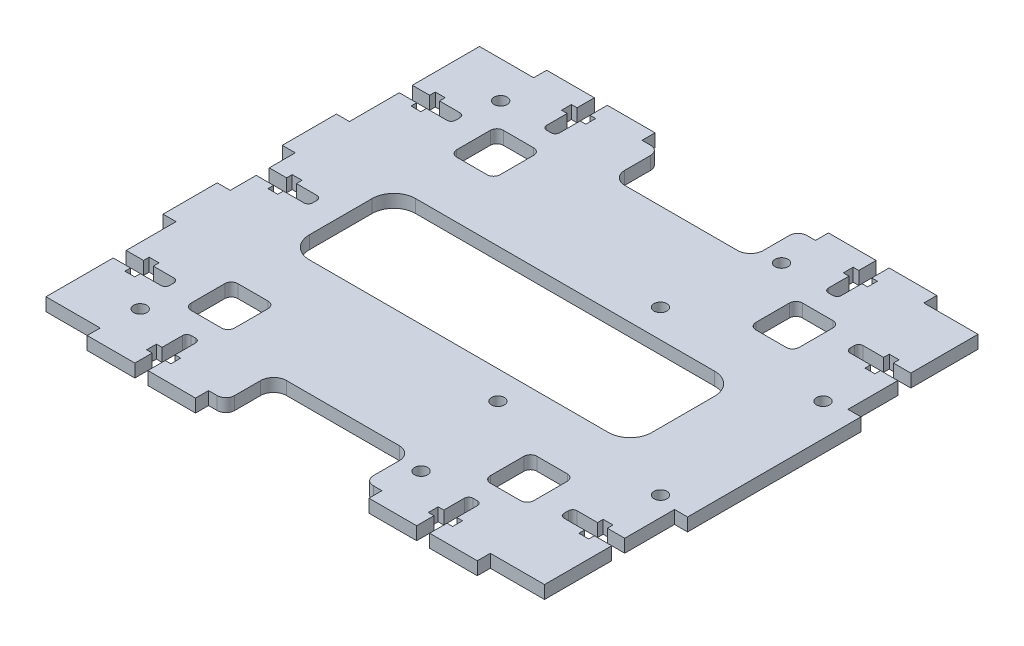
from build123d import *

# Parameters (mm, degrees)
ESBO_O1_W                  = 115
ESBO_O1_H                  = 100
RESSALTO_EXTRUS_O1_DEPTH   = 1.5
ESBO_O4_W                  = 3
ESBO_O4_H                  = 40
ESBO_O4_W_2                = 25
ESBO_O4_H_2                = 3
RESSALTO_EXTRUS_O2_DEPTH   = 3
CORTE_EXTRUS_O1_DEPTH      = 4
CORTE_EXTRUS_O4_DEPTH      = 4
ESBO_O13_R                 = 1.5
CORTE_EXTRUS_O8_DEPTH      = 1
CORTE_EXTRUS_O8_DEPTH_BACK = 4
CUT_EXTRUDE3_DEPTH         = 2.5
CUT_EXTRUDE3_DEPTH_BACK    = 2.5
CUT_EXTRUDE4_DEPTH         = 2.5
CUT_EXTRUDE4_DEPTH_BACK    = 2.5
CUT_EXTRUDE5_DEPTH         = 2.5
CUT_EXTRUDE5_DEPTH_BACK    = 2.5
FILLET1_R                  = 2
CUT_EXTRUDE6_DEPTH         = 2.5
CUT_EXTRUDE6_DEPTH_BACK    = 2.5
SKETCH8_R                  = 1.5
CUT_EXTRUDE7_DEPTH         = 1
CUT_EXTRUDE7_DEPTH_BACK    = 4


with BuildPart() as part:
    # Esboço1 → Ressalto-extrusão1 (new body, symmetric)
    with BuildSketch(Plane(origin=(0, 0, 0), x_dir=(1, 0, 0), z_dir=(0, 1, 0))):
        Rectangle(ESBO_O1_W, ESBO_O1_H)
    extrude(amount=RESSALTO_EXTRUS_O1_DEPTH, both=True)

    # Esboço4 → Ressalto-extrusão2 (add, through all)
    with BuildSketch(Plane(origin=(0, 1.5, 0), x_dir=(1, 0, 0), z_dir=(0, 1, 0))):
        with Locations((-59, 0)):
            Rectangle(ESBO_O4_W, ESBO_O4_H)
        with Locations((-32.5, -51.5)):
            Rectangle(ESBO_O4_W_2, ESBO_O4_H_2)
        with Locations((59, 0)):
            Rectangle(ESBO_O4_W, ESBO_O4_H)
        with Locations((32.5, -51.5)):
            Rectangle(ESBO_O4_W_2, ESBO_O4_H_2)
        with Locations((32.5, 51.5)):
            Rectangle(ESBO_O4_W_2, ESBO_O4_H_2)
        with Locations((-32.5, 51.5)):
            Rectangle(ESBO_O4_W_2, ESBO_O4_H_2)
    extrude(amount=-RESSALTO_EXTRUS_O2_DEPTH)

    # Esboço2 → Corte-extrusão1 (cut, through all)
    with BuildSketch(Plane(origin=(0, 1.5, 0), x_dir=(1, 0, 0), z_dir=(0, 1, 0))):
        with BuildLine():
            Line((-34, -53), (-31, -53))
            Line((-31, -53), (-31, -49))
            Line((-31, -49), (-29.7, -49))
            Line((-29.7, -49), (-29.7, -46.73))
            Line((-29.7, -46.73), (-31, -46.73))
            Line((-31, -46.73), (-31, -42))
            ThreePointArc((-31, -42), (-31.292893219, -41.292893219), (-32, -41))
            Line((-32, -41), (-33, -41))
            ThreePointArc((-33, -41), (-33.707106781, -41.292893219), (-34, -42))
            Line((-34, -42), (-34, -46.73))
            Line((-34, -46.73), (-35.3, -46.73))
            Line((-35.3, -46.73), (-35.3, -49))
            Line((-35.3, -49), (-34, -49))
            Line((-34, -49), (-34, -53))
        make_face()
        with BuildLine():
            Line((31, -46.73), (31, -42))
            ThreePointArc((31, -42), (31.292893219, -41.292893219), (32, -41))
            Line((32, -41), (33, -41))
            ThreePointArc((33, -41), (33.707106781, -41.292893219), (34, -42))
            Line((34, -42), (34, -46.73))
            Line((34, -46.73), (35.3, -46.73))
            Line((35.3, -46.73), (35.3, -49))
            Line((35.3, -49), (34, -49))
            Line((34, -49), (34, -53))
            Line((34, -53), (31, -53))
            Line((31, -53), (31, -49))
            Line((31, -49), (29.7, -49))
            Line((29.7, -49), (29.7, -46.73))
            Line((29.7, -46.73), (31, -46.73))
        make_face()
        with BuildLine():
            Line((34, 53), (31, 53))
            Line((31, 53), (31, 49))
            Line((31, 49), (29.7, 49))
            Line((29.7, 49), (29.7, 46.73))
            Line((29.7, 46.73), (31, 46.73))
            Line((31, 46.73), (31, 42))
            ThreePointArc((31, 42), (31.292893219, 41.292893219), (32, 41))
            Line((32, 41), (33, 41))
            ThreePointArc((33, 41), (33.707106781, 41.292893219), (34, 42))
            Line((34, 42), (34, 46.73))
            Line((34, 46.73), (35.3, 46.73))
            Line((35.3, 46.73), (35.3, 49))
            Line((35.3, 49), (34, 49))
            Line((34, 49), (34, 53))
        make_face()
        with BuildLine():
            Line((-31, 46.73), (-31, 42))
            ThreePointArc((-31, 42), (-31.292893219, 41.292893219), (-32, 41))
            Line((-32, 41), (-33, 41))
            ThreePointArc((-33, 41), (-33.707106781, 41.292893219), (-34, 42))
            Line((-34, 42), (-34, 46.73))
            Line((-34, 46.73), (-35.3, 46.73))
            Line((-35.3, 46.73), (-35.3, 49))
            Line((-35.3, 49), (-34, 49))
            Line((-34, 49), (-34, 53))
            Line((-34, 53), (-31, 53))
            Line((-31, 53), (-31, 49))
            Line((-31, 49), (-29.7, 49))
            Line((-29.7, 49), (-29.7, 46.73))
            Line((-29.7, 46.73), (-31, 46.73))
        make_face()
    extrude(amount=-CORTE_EXTRUS_O1_DEPTH, mode=Mode.SUBTRACT)

    # Esboço7 → Corte-extrusão4 (cut, through all)
    with BuildSketch(Plane(origin=(0, 1.5, 0), x_dir=(1, 0, 0), z_dir=(0, 1, 0))):
        with BuildLine():
            Line((-57.5, -31.5), (-53.5, -31.5))
            Line((-53.5, -31.5), (-53.5, -30.2))
            Line((-53.5, -30.2), (-51.23, -30.2))
            Line((-51.23, -30.2), (-51.23, -31.5))
            Line((-51.23, -31.5), (-46.5, -31.5))
            ThreePointArc((-46.5, -31.5), (-45.792893219, -31.792893219), (-45.5, -32.5))
            Line((-45.5, -32.5), (-45.5, -33.5))
            ThreePointArc((-45.5, -33.5), (-45.792893219, -34.207106781), (-46.5, -34.5))
            Line((-46.5, -34.5), (-51.23, -34.5))
            Line((-51.23, -34.5), (-51.23, -35.8))
            Line((-51.23, -35.8), (-53.5, -35.8))
            Line((-53.5, -35.8), (-53.5, -34.5))
            Line((-53.5, -34.5), (-57.5, -34.5))
            Line((-57.5, -34.5), (-57.5, -31.5))
        make_face()
        with BuildLine():
            Line((53.5, -34.5), (53.5, -35.8))
            Line((53.5, -35.8), (51.23, -35.8))
            Line((51.23, -35.8), (51.23, -34.5))
            Line((51.23, -34.5), (46.5, -34.5))
            ThreePointArc((46.5, -34.5), (45.792893219, -34.207106781), (45.5, -33.5))
            Line((45.5, -33.5), (45.5, -32.5))
            ThreePointArc((45.5, -32.5), (45.792893219, -31.792893219), (46.5, -31.5))
            Line((46.5, -31.5), (51.23, -31.5))
            Line((51.23, -31.5), (51.23, -30.2))
            Line((51.23, -30.2), (53.5, -30.2))
            Line((53.5, -30.2), (53.5, -31.5))
            Line((53.5, -31.5), (57.5, -31.5))
            Line((57.5, -31.5), (57.5, -34.5))
            Line((57.5, -34.5), (53.5, -34.5))
        make_face()
        with BuildLine():
            Line((57.5, 31.5), (53.5, 31.5))
            Line((53.5, 31.5), (53.5, 30.2))
            Line((53.5, 30.2), (51.23, 30.2))
            Line((51.23, 30.2), (51.23, 31.5))
            Line((51.23, 31.5), (46.5, 31.5))
            ThreePointArc((46.5, 31.5), (45.792893219, 31.792893219), (45.5, 32.5))
            Line((45.5, 32.5), (45.5, 33.5))
            ThreePointArc((45.5, 33.5), (45.792893219, 34.207106781), (46.5, 34.5))
            Line((46.5, 34.5), (51.23, 34.5))
            Line((51.23, 34.5), (51.23, 35.8))
            Line((51.23, 35.8), (53.5, 35.8))
            Line((53.5, 35.8), (53.5, 34.5))
            Line((53.5, 34.5), (57.5, 34.5))
            Line((57.5, 34.5), (57.5, 31.5))
        make_face()
        with BuildLine():
            Line((-53.5, 34.5), (-53.5, 35.8))
            Line((-53.5, 35.8), (-51.23, 35.8))
            Line((-51.23, 35.8), (-51.23, 34.5))
            Line((-51.23, 34.5), (-46.5, 34.5))
            ThreePointArc((-46.5, 34.5), (-45.792893219, 34.207106781), (-45.5, 33.5))
            Line((-45.5, 33.5), (-45.5, 32.5))
            ThreePointArc((-45.5, 32.5), (-45.792893219, 31.792893219), (-46.5, 31.5))
            Line((-46.5, 31.5), (-51.23, 31.5))
            Line((-51.23, 31.5), (-51.23, 30.2))
            Line((-51.23, 30.2), (-53.5, 30.2))
            Line((-53.5, 30.2), (-53.5, 31.5))
            Line((-53.5, 31.5), (-57.5, 31.5))
            Line((-57.5, 31.5), (-57.5, 34.5))
            Line((-57.5, 34.5), (-53.5, 34.5))
        make_face()
    extrude(amount=-CORTE_EXTRUS_O4_DEPTH, mode=Mode.SUBTRACT)

    # Esboço13 → Corte-extrusão8 (cut, two sides)
    with BuildSketch(Plane(origin=(0, -1.5, 0), x_dir=(-1, 0, 0), z_dir=(0, -1, 0))) as corte_extrus_o8_sk:
        with Locations((-15.5, -18.75)):
            Circle(ESBO_O13_R)
        with Locations((-53, -18.75)):
            Circle(ESBO_O13_R)
        with Locations((-15.5, 18.75)):
            Circle(ESBO_O13_R)
        with Locations((-53, 18.75)):
            Circle(ESBO_O13_R)
    extrude(amount=CORTE_EXTRUS_O8_DEPTH, mode=Mode.SUBTRACT)
    extrude(corte_extrus_o8_sk.sketch, amount=-CORTE_EXTRUS_O8_DEPTH_BACK, mode=Mode.SUBTRACT)

    # Sketch4 → Cut-Extrude3 (cut, two sides)
    with BuildSketch(Plane(origin=(0, 0, 0), x_dir=(1, 0, 0), z_dir=(0, 1, 0))) as cut_extrude3_sk:
        with BuildLine():
            Line((-38, 36), (-31, 36))
            ThreePointArc((-31, 36), (-29.939339828, 35.560660172), (-29.5, 34.5))
            Line((-29.5, 34.5), (-29.5, 26.75))
            ThreePointArc((-29.5, 26.75), (-29.939339828, 25.689339828), (-31, 25.25))
            Line((-31, 25.25), (-38, 25.25))
            ThreePointArc((-38, 25.25), (-39.060660172, 25.689339828), (-39.5, 26.75))
            Line((-39.5, 26.75), (-39.5, 34.5))
            ThreePointArc((-39.5, 34.5), (-39.060660172, 35.560660172), (-38, 36))
        make_face()
        with BuildLine():
            Line((29.5, 34.5), (29.5, 26.75))
            ThreePointArc((29.5, 26.75), (29.939339828, 25.689339828), (31, 25.25))
            Line((31, 25.25), (38, 25.25))
            ThreePointArc((38, 25.25), (39.060660172, 25.689339828), (39.5, 26.75))
            Line((39.5, 26.75), (39.5, 34.5))
            ThreePointArc((39.5, 34.5), (39.060660172, 35.560660172), (38, 36))
            Line((38, 36), (31, 36))
            ThreePointArc((31, 36), (29.939339828, 35.560660172), (29.5, 34.5))
        make_face()
        with BuildLine():
            Line((38, -36), (31, -36))
            ThreePointArc((31, -36), (29.939339828, -35.560660172), (29.5, -34.5))
            Line((29.5, -34.5), (29.5, -26.75))
            ThreePointArc((29.5, -26.75), (29.939339828, -25.689339828), (31, -25.25))
            Line((31, -25.25), (38, -25.25))
            ThreePointArc((38, -25.25), (39.060660172, -25.689339828), (39.5, -26.75))
            Line((39.5, -26.75), (39.5, -34.5))
            ThreePointArc((39.5, -34.5), (39.060660172, -35.560660172), (38, -36))
        make_face()
        with BuildLine():
            Line((-29.5, -34.5), (-29.5, -26.75))
            ThreePointArc((-29.5, -26.75), (-29.939339828, -25.689339828), (-31, -25.25))
            Line((-31, -25.25), (-38, -25.25))
            ThreePointArc((-38, -25.25), (-39.060660172, -25.689339828), (-39.5, -26.75))
            Line((-39.5, -26.75), (-39.5, -34.5))
            ThreePointArc((-39.5, -34.5), (-39.060660172, -35.560660172), (-38, -36))
            Line((-38, -36), (-31, -36))
            ThreePointArc((-31, -36), (-29.939339828, -35.560660172), (-29.5, -34.5))
        make_face()
    extrude(amount=CUT_EXTRUDE3_DEPTH, mode=Mode.SUBTRACT)
    extrude(cut_extrude3_sk.sketch, amount=-CUT_EXTRUDE3_DEPTH_BACK, mode=Mode.SUBTRACT)

    # Sketch5 → Cut-Extrude4 (cut, two sides)
    with BuildSketch(Plane(origin=(0, 0, 0), x_dir=(1, 0, 0), z_dir=(0, 1, 0))) as cut_extrude4_sk:
        with BuildLine():
            Line((-60.5, 7.5), (-57.5, 7.5))
            Line((-57.5, 7.5), (-57.5, 1.5))
            Line((-57.5, 1.5), (-53.5, 1.5))
            Line((-53.5, 1.5), (-53.5, 2.8))
            Line((-53.5, 2.8), (-51.23, 2.8))
            Line((-51.23, 2.8), (-51.23, 1.5))
            Line((-51.23, 1.5), (-46.5, 1.5))
            ThreePointArc((-46.5, 1.5), (-45.792893219, 1.207106781), (-45.5, 0.5))
            Line((-45.5, 0.5), (-45.5, -0.5))
            ThreePointArc((-45.5, -0.5), (-45.792893219, -1.207106781), (-46.5, -1.5))
            Line((-46.5, -1.5), (-51.23, -1.5))
            Line((-51.23, -1.5), (-51.23, -2.8))
            Line((-51.23, -2.8), (-53.5, -2.8))
            Line((-53.5, -2.8), (-53.5, -1.5))
            Line((-53.5, -1.5), (-57.5, -1.5))
            Line((-57.5, -1.5), (-57.5, -7.5))
            Line((-57.5, -7.5), (-60.5, -7.5))
            Line((-60.5, -7.5), (-60.5, 7.5))
        make_face()
    extrude(amount=CUT_EXTRUDE4_DEPTH, mode=Mode.SUBTRACT)
    extrude(cut_extrude4_sk.sketch, amount=-CUT_EXTRUDE4_DEPTH_BACK, mode=Mode.SUBTRACT)

    # Sketch6 → Cut-Extrude5 (cut, two sides)
    with BuildSketch(Plane(origin=(0, 0, 0), x_dir=(1, 0, 0), z_dir=(0, 1, 0))) as cut_extrude5_sk:
        with BuildLine():
            Line((-16, -50), (16, -50))
            Line((16, -50), (16, -42))
            ThreePointArc((16, -42), (15.121320344, -39.878679656), (13, -39))
            Line((13, -39), (-13, -39))
            ThreePointArc((-13, -39), (-15.121320344, -39.878679656), (-16, -42))
            Line((-16, -42), (-16, -50))
        make_face()
        with BuildLine():
            Line((16, 50), (16, 42))
            ThreePointArc((16, 42), (15.121320344, 39.878679656), (13, 39))
            Line((13, 39), (-13, 39))
            ThreePointArc((-13, 39), (-15.121320344, 39.878679656), (-16, 42))
            Line((-16, 42), (-16, 50))
            Line((-16, 50), (16, 50))
        make_face()
    extrude(amount=CUT_EXTRUDE5_DEPTH, mode=Mode.SUBTRACT)
    extrude(cut_extrude5_sk.sketch, amount=-CUT_EXTRUDE5_DEPTH_BACK, mode=Mode.SUBTRACT)

    # Fillet1
    fillet1_edges = [part.edges().sort_by_distance(p)[0] for p in [
        (-16, 0, 50),
        (16, 0, 50),
        (-16, 0, -50),
        (16, 0, -50),
    ]]
    fillet(fillet1_edges, radius=FILLET1_R)

    # Sketch7 → Cut-Extrude6 (cut, two sides)
    with BuildSketch(Plane(origin=(0, 0, 0), x_dir=(1, 0, 0), z_dir=(0, 1, 0))) as cut_extrude6_sk:
        with BuildLine():
            Line((-34.5, -12.25), (34.5, -12.25))
            ThreePointArc((34.5, -12.25), (38.035533906, -10.785533906), (39.5, -7.25))
            Line((39.5, -7.25), (39.5, 7.25))
            ThreePointArc((39.5, 7.25), (38.035533906, 10.785533906), (34.5, 12.25))
            Line((34.5, 12.25), (-34.5, 12.25))
            ThreePointArc((-34.5, 12.25), (-38.035533906, 10.785533906), (-39.5, 7.25))
            Line((-39.5, 7.25), (-39.5, -7.25))
            ThreePointArc((-39.5, -7.25), (-38.035533906, -10.785533906), (-34.5, -12.25))
        make_face()
    extrude(amount=CUT_EXTRUDE6_DEPTH, mode=Mode.SUBTRACT)
    extrude(cut_extrude6_sk.sketch, amount=-CUT_EXTRUDE6_DEPTH_BACK, mode=Mode.SUBTRACT)

    # Sketch8 → Cut-Extrude7 (cut, two sides)
    with BuildSketch(Plane(origin=(0, 1.5, 0), x_dir=(1, 0, 0), z_dir=(0, 1, 0))) as cut_extrude7_sk:
        with Locations((-44.2, -41.58)):
            Circle(SKETCH8_R)
        with Locations((-44.2, 41.58)):
            Circle(SKETCH8_R)
        with Locations((20.6, -41.58)):
            Circle(SKETCH8_R)
        with Locations((20.6, 41.58)):
            Circle(SKETCH8_R)
    extrude(amount=CUT_EXTRUDE7_DEPTH, mode=Mode.SUBTRACT)
    extrude(cut_extrude7_sk.sketch, amount=-CUT_EXTRUDE7_DEPTH_BACK, mode=Mode.SUBTRACT)


solid = part.part
